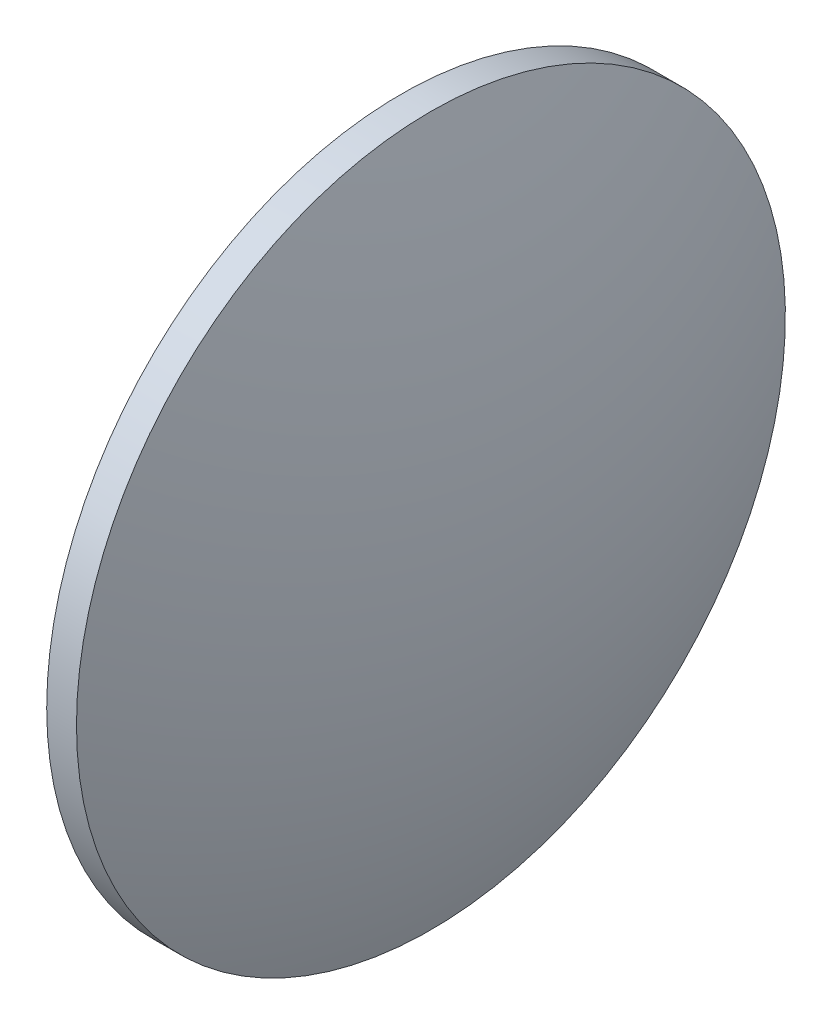
from build123d import *


with BuildPart() as part:
    # 草图1 → 旋转1 (revolve)
    with BuildSketch(Plane.XY):
        with BuildLine():
            Line((443.463520319, 60.46347484), (443.463520319, 82.96347484))
            Line((443.463520319, 82.96347484), (445.353520319, 82.96347484))
            ThreePointArc((445.353520319, 82.96347484), (448.50196598, 71.908715118), (449.563520319, 60.46347484))
            Line((449.563520319, 60.46347484), (443.463520319, 60.46347484))
        make_face()
    revolve(axis=Axis((434.028740434, 60.46347484, 0), (1, 0, 0)))


solid = part.part
